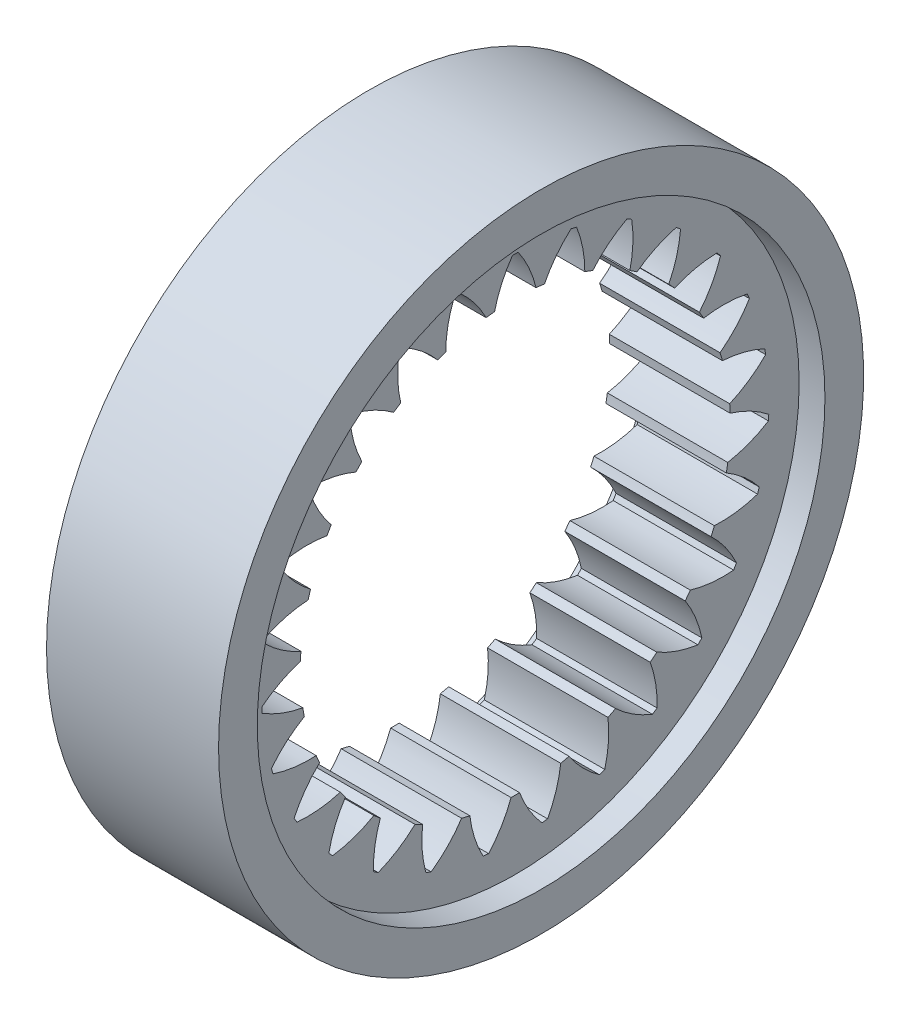
from build123d import *

# Parameters (mm, degrees)
BASPROSKE_W        = 20
BASPROSKE_H        = 12.5
TOOTHCUT_DEPTH     = 57.678920244
TEETHCUTS_COUNT    = 27
TEETHCUTS_ANGLE    = 346.666666667
SKETCH1_R          = 33
CUT_EXTRUDE1_DEPTH = 3
CUT_EXTRUDE2_START = -3
SKETCH2_R          = 33
CUT_EXTRUDE2_DEPTH = 3


with BuildPart() as part:
    # BasProSke → Base-Revolve (revolve)
    with BuildSketch(Plane(origin=(0, 0, 0), x_dir=(1, 0, 0), z_dir=(0, 1, 0))):
        with Locations((10, 31.25)):
            Rectangle(BASPROSKE_W, BASPROSKE_H)
    revolve(axis=Axis((-10, 0, 0), (1, 0, 0)))

    # TooCutSke → ToothCut (cut, through all)
    with BuildSketch(Plane(origin=(0, 0, 0), x_dir=(0, 0, -1), z_dir=(1, 0, 0))):
        with BuildLine():
            ThreePointArc((2.416400206, 24.85742656), (1.592639823, 27.277654117), (0.32737703, 29.499183468))
            ThreePointArc((0.32737703, 29.499183468), (0, 29.501), (-0.32737703, 29.499183468))
            ThreePointArc((-0.32737703, 29.499183468), (-1.592639823, 27.277654117), (-2.416400206, 24.85742656))
            ThreePointArc((-2.416400206, 24.85742656), (0, 24.9746), (2.416400206, 24.85742656))
        make_face()
    toothcut = extrude(amount=TOOTHCUT_DEPTH, mode=Mode.SUBTRACT)

    # TeethCuts: ToothCut ×27 about axis
    teethcuts_axis = Axis((-10, 0, 0), (1, 0, 0))
    for i in range(1, TEETHCUTS_COUNT):
        add(toothcut.rotate(teethcuts_axis, i * TEETHCUTS_ANGLE / (TEETHCUTS_COUNT - 1)), mode=Mode.SUBTRACT)

    # Sketch1 → Cut-Extrude1 (cut)
    with BuildSketch(Plane(origin=(20, 0, 0), x_dir=(0, 0, -1), z_dir=(1, 0, 0))):
        Circle(SKETCH1_R)
    extrude(amount=-CUT_EXTRUDE1_DEPTH, mode=Mode.SUBTRACT)

    # Sketch2 → Cut-Extrude2 (cut)
    with BuildSketch(Plane.ZY.offset(CUT_EXTRUDE2_START)):
        Circle(SKETCH2_R)
    extrude(amount=CUT_EXTRUDE2_DEPTH, mode=Mode.SUBTRACT)


solid = part.part
